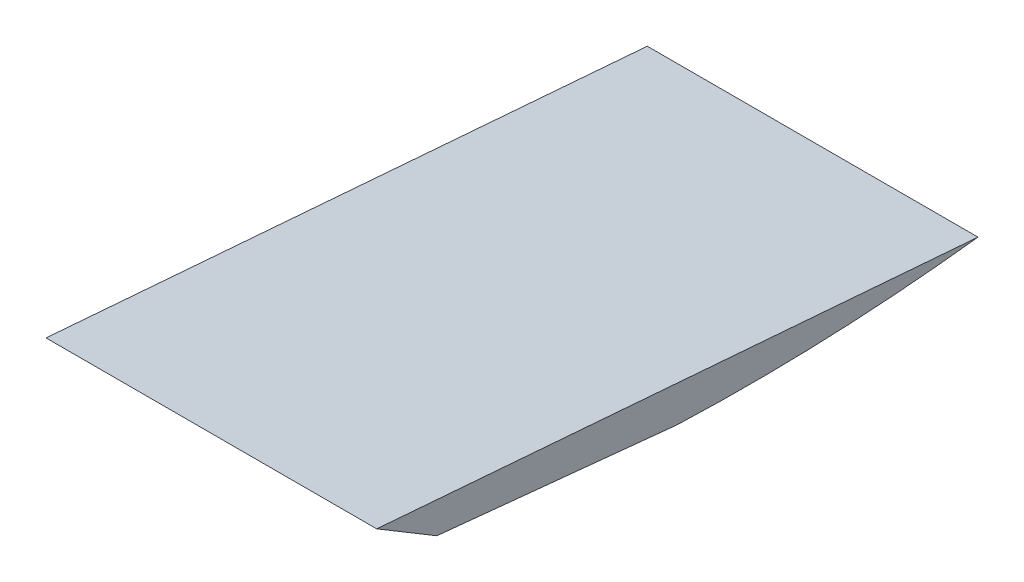
from build123d import *

# Parameters (mm, degrees)
EXTRUDE_1_DEPTH = 13.75


with BuildPart() as part:
    # 스케치2 → 보스-돌출1 (new body, symmetric)
    with BuildSketch(Plane(origin=(0, 0, 0), x_dir=(0, 0, -1), z_dir=(1, 0, 0))):
        with BuildLine():
            Line((0, 0), (20, -2))
            ThreePointArc((20, -2), (32.519706897, -1.98610958), (45, -0.993367008))
            Line((45, -0.993367008), (-5, 3))
            Line((-5, 3), (0, 0))
        make_face()
    extrude(amount=EXTRUDE_1_DEPTH, both=True)


solid = part.part
